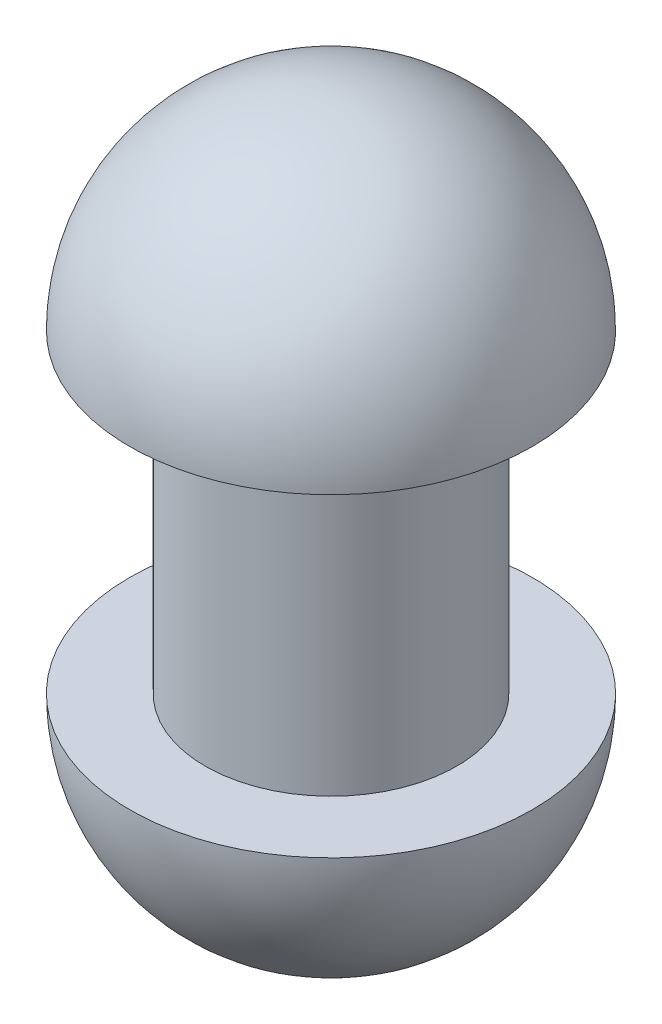
from build123d import *


with BuildPart() as part:
    # Sketch1 → Revolve1 (revolve)
    with BuildSketch(Plane.XY):
        with BuildLine():
            Line((6.773952861, -3.765306122), (6.773952861, 18.734693878))
            Line((6.773952861, 18.734693878), (12.173952861, 18.734693878))
            ThreePointArc((12.173952861, 18.734693878), (7.95629051, 28.917031527), (-2.226047139, 33.134693878))
            Line((-2.226047139, 33.134693878), (-2.226047139, -18.165306122))
            ThreePointArc((-2.226047139, -18.165306122), (7.95629051, -13.947643772), (12.173952861, -3.765306122))
            Line((12.173952861, -3.765306122), (6.773952861, -3.765306122))
        make_face()
    revolve(axis=Axis((-2.226047139, 33.134693878, 0), (0, -1, 0)))


solid = part.part
